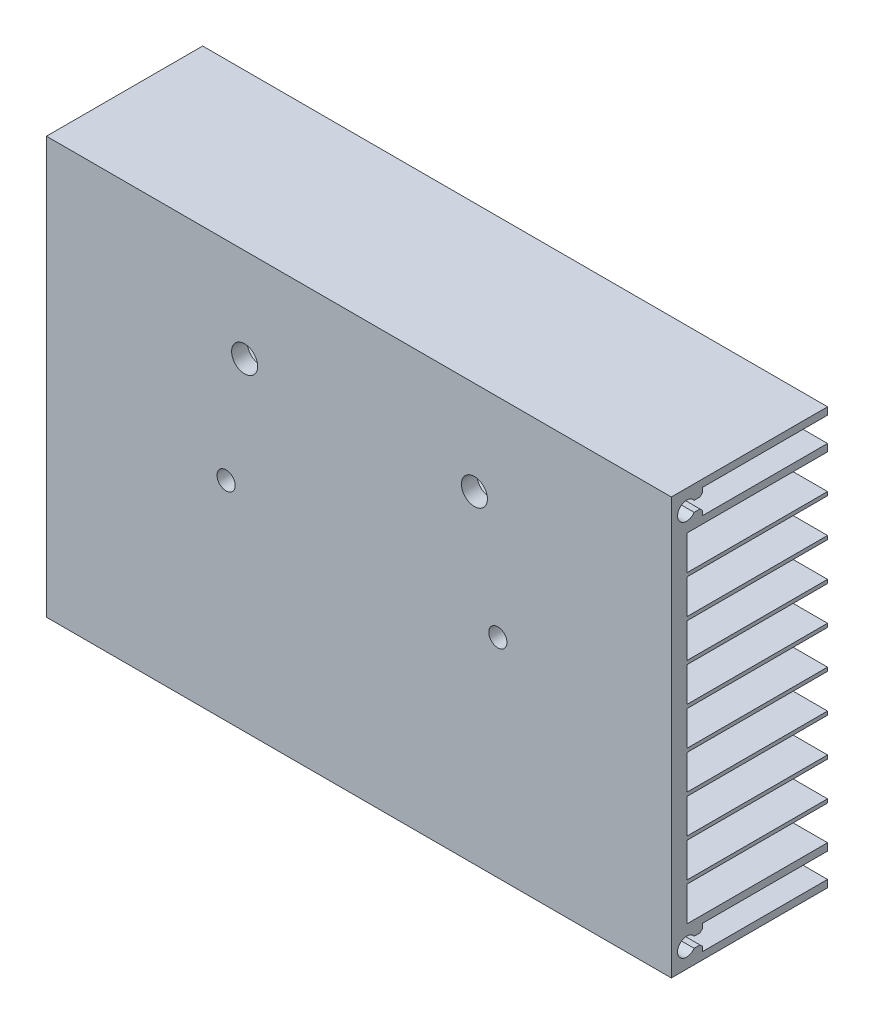
from build123d import *

# Parameters (mm, degrees)
SCHIZZO1_W                   = 120
SCHIZZO1_H                   = 80
ESTRUSIONE_ESTRUSIONE1_DEPTH = 30
SCHIZZO2_W                   = 27
SCHIZZO2_H                   = 6.6
TAGLIO_ESTRUSIONE1_DEPTH     = 121
RIPETIZIONE_A_L1_COUNT       = 9
RIPETIZIONE_A_L1_PITCH       = 7.3
SCHIZZO3_W                   = 24
SCHIZZO3_H                   = 4.7
TAGLIO_ESTRUSIONE2_DEPTH     = 121
TAGLIO_ESTRUSIONE3_DEPTH     = 121
SMUSSO1_SIZE                 = 0.5
SCHIZZO5_R                   = 1.75
SCHIZZO5_R_2                 = 2.5
TAGLIO_ESTRUSIONE4_DEPTH     = 10


with BuildPart() as part:
    # Schizzo1 → Estrusione-Estrusione1 (new body)
    with BuildSketch(Plane.XY):
        Rectangle(SCHIZZO1_W, SCHIZZO1_H)
    extrude(amount=ESTRUSIONE_ESTRUSIONE1_DEPTH)

    # Schizzo2 → Taglio-Estrusione1 (cut, through all)
    with BuildSketch(Plane.ZY.offset(60)):
        with Locations((13.5, -29.2)):
            Rectangle(SCHIZZO2_W, SCHIZZO2_H)
    taglio_estrusione1 = extrude(amount=-TAGLIO_ESTRUSIONE1_DEPTH, mode=Mode.SUBTRACT)

    # Ripetizione a L1: Taglio-Estrusione1 ×9
    with Locations(*[(0, i * RIPETIZIONE_A_L1_PITCH, 0) for i in range(1, RIPETIZIONE_A_L1_COUNT)]):
        add(taglio_estrusione1, mode=Mode.SUBTRACT)

    # Schizzo3 → Taglio-Estrusione2 (cut, through all)
    with BuildSketch(Plane(origin=(60, 0, 0), x_dir=(0, 0, -1), z_dir=(1, 0, 0))):
        with Locations((-12, -36.25)):
            Rectangle(SCHIZZO3_W, SCHIZZO3_H)
        with Locations((-12, 36.25)):
            Rectangle(SCHIZZO3_W, SCHIZZO3_H)
    extrude(amount=-TAGLIO_ESTRUSIONE2_DEPTH, mode=Mode.SUBTRACT)

    # Schizzo4 → Taglio-Estrusione3 (cut, through all)
    with BuildSketch(Plane(origin=(60, 0, 0), x_dir=(0, 0, -1), z_dir=(1, 0, 0))):
        with BuildLine():
            ThreePointArc((-25.3, 36.25), (-25.38030749, 35.725951413), (-25.613859338, 35.25))
            Line((-25.613859338, 35.25), (-24, 35.25))
            Line((-24, 35.25), (-24, 37.25))
            Line((-24, 37.25), (-25.613859338, 37.25))
            ThreePointArc((-25.613859338, 37.25), (-25.38030749, 36.774048587), (-25.3, 36.25))
        make_face()
        with BuildLine():
            Line((-27.05, 37.25), (-27.05, 35.25))
            Line((-27.05, 35.25), (-25.613859338, 35.25))
            ThreePointArc((-25.613859338, 35.25), (-25.38030749, 35.725951413), (-25.3, 36.25))
            ThreePointArc((-25.3, 36.25), (-25.38030749, 36.774048587), (-25.613859338, 37.25))
            Line((-25.613859338, 37.25), (-27.05, 37.25))
        make_face()
        with BuildLine():
            Line((-25.613859338, 35.25), (-27.05, 35.25))
            Line((-27.05, 35.25), (-27.05, 37.25))
            Line((-27.05, 37.25), (-25.613859338, 37.25))
            ThreePointArc((-25.613859338, 37.25), (-28.8, 36.25), (-25.613859338, 35.25))
        make_face()
        with BuildLine():
            ThreePointArc((-25.3, -36.25), (-25.38030749, -35.725951413), (-25.613859338, -35.25))
            Line((-25.613859338, -35.25), (-27.05, -35.25))
            Line((-27.05, -35.25), (-27.05, -37.25))
            Line((-27.05, -37.25), (-25.613859338, -37.25))
            ThreePointArc((-25.613859338, -37.25), (-25.38030749, -36.774048587), (-25.3, -36.25))
        make_face()
        with BuildLine():
            Line((-27.05, -35.25), (-25.613859338, -35.25))
            ThreePointArc((-25.613859338, -35.25), (-28.8, -36.25), (-25.613859338, -37.25))
            Line((-25.613859338, -37.25), (-27.05, -37.25))
            Line((-27.05, -37.25), (-27.05, -35.25))
        make_face()
        with BuildLine():
            Line((-24, -37.25), (-24, -35.25))
            Line((-24, -35.25), (-25.613859338, -35.25))
            ThreePointArc((-25.613859338, -35.25), (-25.38030749, -35.725951413), (-25.3, -36.25))
            ThreePointArc((-25.3, -36.25), (-25.38030749, -36.774048587), (-25.613859338, -37.25))
            Line((-25.613859338, -37.25), (-24, -37.25))
        make_face()
    extrude(amount=-TAGLIO_ESTRUSIONE3_DEPTH, mode=Mode.SUBTRACT)

    # Smusso1
    smusso1_edges = [part.edges().sort_by_distance(p)[0] for p in [
        (0, 37.25, 24),
        (0, 35.25, 24),
        (0, -35.25, 24),
        (0, -37.25, 24),
    ]]
    chamfer(smusso1_edges, length=SMUSSO1_SIZE)

    # Schizzo5 → Taglio-Estrusione4 (cut)
    with BuildSketch(Plane.XY.offset(30)):
        with Locations((-25.5, 0)):
            Circle(SCHIZZO5_R)
        with Locations((26.686198964, 0)):
            Circle(SCHIZZO5_R)
        with Locations((-21.944553743, 22)):
            Circle(SCHIZZO5_R_2)
        with Locations((22.18196976, 22)):
            Circle(SCHIZZO5_R_2)
    extrude(amount=-TAGLIO_ESTRUSIONE4_DEPTH, mode=Mode.SUBTRACT)


solid = part.part
